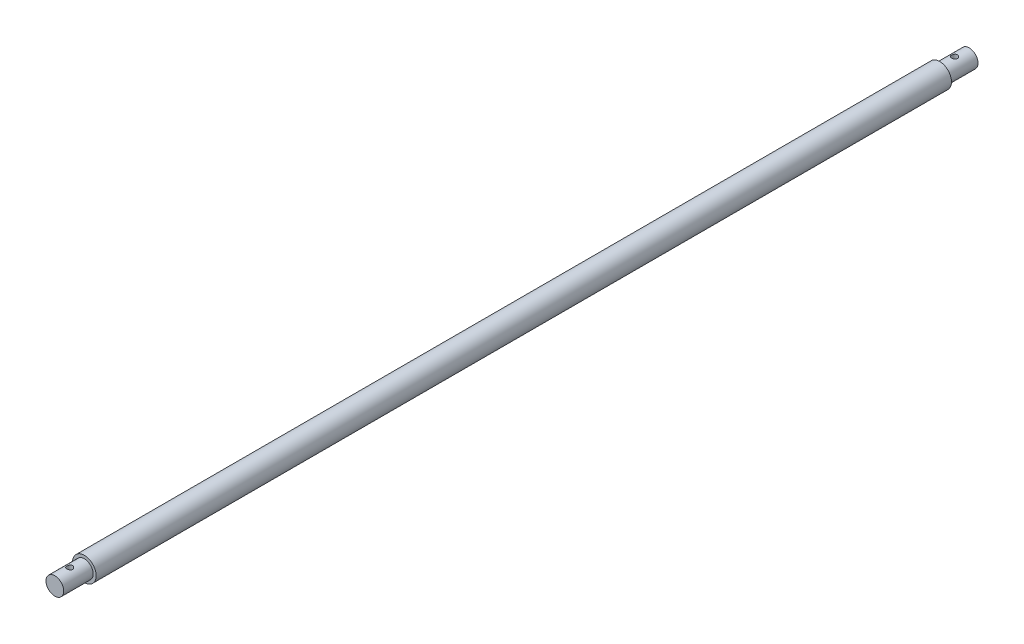
from build123d import *

# Parameters (mm, degrees)
SKETCH1_R           = 4
BOSS_EXTRUDE1_DEPTH = 300
SKETCH2_R           = 3
BOSS_EXTRUDE2_DEPTH = 10
SKETCH3_R           = 1
CUT_EXTRUDE1_DEPTH  = 3
SKETCH4_R           = 4
SKETCH4_R_2         = 3
CUT_EXTRUDE2_DEPTH  = 10
SKETCH5_R           = 1
CUT_EXTRUDE3_DEPTH  = 3


with BuildPart() as part:
    # Sketch1 → Boss-Extrude1 (new body)
    with BuildSketch(Plane.XY):
        Circle(SKETCH1_R)
    extrude(amount=BOSS_EXTRUDE1_DEPTH)

    # Sketch2 → Boss-Extrude2 (add)
    with BuildSketch(Plane.XY.offset(300)):
        Circle(SKETCH2_R)
    extrude(amount=BOSS_EXTRUDE2_DEPTH)

    # Sketch3 → Cut-Extrude1 (cut, symmetric)
    with BuildSketch(Plane(origin=(0, 0, 0), x_dir=(1, 0, 0), z_dir=(0, 1, 0))):
        with Locations((0, -305)):
            Circle(SKETCH3_R)
    extrude(amount=CUT_EXTRUDE1_DEPTH, both=True, mode=Mode.SUBTRACT)

    # Sketch4 → Cut-Extrude2 (cut)
    with BuildSketch(Plane(origin=(0, 0, 0), x_dir=(-1, 0, 0), z_dir=(0, 0, -1))):
        Circle(SKETCH4_R)
        Circle(SKETCH4_R_2, mode=Mode.SUBTRACT)
    extrude(amount=-CUT_EXTRUDE2_DEPTH, mode=Mode.SUBTRACT)

    # Sketch5 → Cut-Extrude3 (cut, symmetric)
    with BuildSketch(Plane(origin=(0, 0, 0), x_dir=(1, 0, 0), z_dir=(0, 1, 0))):
        with Locations((0, -5)):
            Circle(SKETCH5_R)
    extrude(amount=CUT_EXTRUDE3_DEPTH, both=True, mode=Mode.SUBTRACT)


solid = part.part
